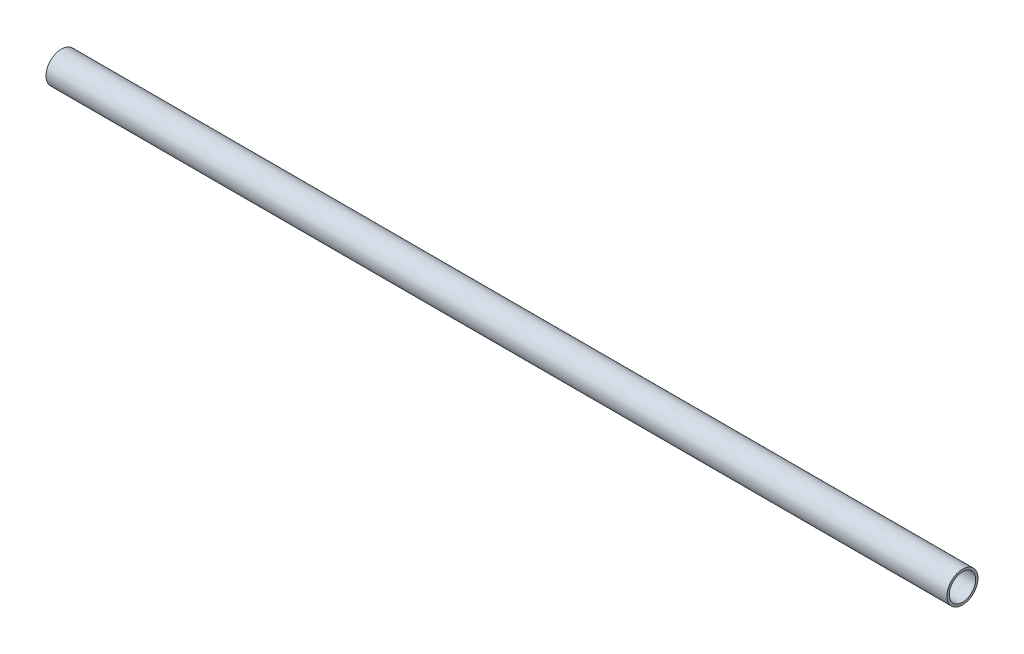
from build123d import *

# Parameters (mm, degrees)
SKETCH1_R           = 12.7
SKETCH1_R_2         = 10.795
BOSS_EXTRUDE1_DEPTH = 736.6
SKETCH3_R           = 1.5875
CUT_EXTRUDE2_DEPTH  = 13.7


with BuildPart() as part:
    # Sketch1 → Boss-Extrude1 (new body)
    with BuildSketch(Plane(origin=(0, 0, 0), x_dir=(0, 0, -1), z_dir=(1, 0, 0))):
        Circle(SKETCH1_R)
        Circle(SKETCH1_R_2, mode=Mode.SUBTRACT)
    extrude(amount=BOSS_EXTRUDE1_DEPTH)

    # Sketch3 → Cut-Extrude2 (cut, through all)
    with BuildSketch(Plane.XY):
        with Locations((50.8, 0)):
            Circle(SKETCH3_R)
        with Locations((101.6, 0)):
            Circle(SKETCH3_R)
        with Locations((152.4, 0)):
            Circle(SKETCH3_R)
        with Locations((203.2, 0)):
            Circle(SKETCH3_R)
        with Locations((254, 0)):
            Circle(SKETCH3_R)
        with Locations((304.8, 0)):
            Circle(SKETCH3_R)
        with Locations((355.6, 0)):
            Circle(SKETCH3_R)
        with Locations((406.4, 0)):
            Circle(SKETCH3_R)
        with Locations((457.2, 0)):
            Circle(SKETCH3_R)
        with Locations((508, 0)):
            Circle(SKETCH3_R)
        with Locations((558.8, 0)):
            Circle(SKETCH3_R)
        with Locations((609.6, 0)):
            Circle(SKETCH3_R)
        with Locations((660.4, 0)):
            Circle(SKETCH3_R)
        with Locations((711.2, 0)):
            Circle(SKETCH3_R)
    extrude(amount=-CUT_EXTRUDE2_DEPTH, mode=Mode.SUBTRACT)


solid = part.part
